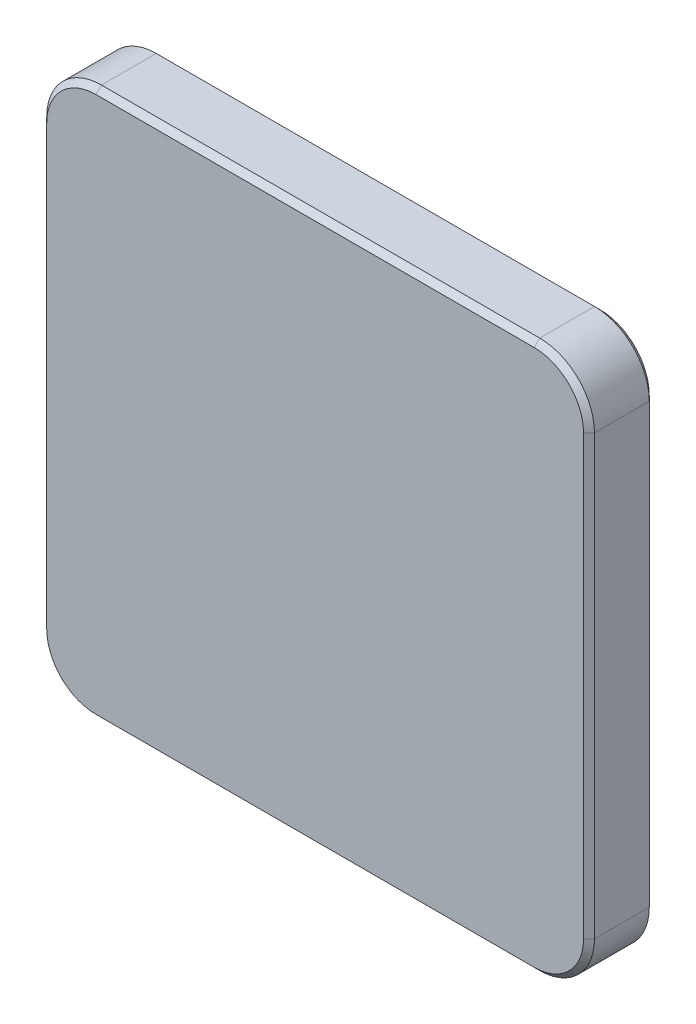
from build123d import *

# Parameters (mm, degrees)
SKETCH1_W           = 100
SKETCH1_H           = 100
BOSS_EXTRUDE1_DEPTH = 12
FILLET1_R           = 10
CHAMFER1_SIZE       = 1
CHAMFER2_SIZE       = 1


with BuildPart() as part:
    # Sketch1 → Boss-Extrude1 (new body)
    with BuildSketch(Plane.XY):
        Rectangle(SKETCH1_W, SKETCH1_H)
    extrude(amount=BOSS_EXTRUDE1_DEPTH)

    # Fillet1
    fillet1_edges = [part.edges().sort_by_distance(p)[0] for p in [
        (50, -50, 6),
        (-50, -50, 6),
        (-50, 50, 6),
        (50, 50, 6),
    ]]
    fillet(fillet1_edges, radius=FILLET1_R)

    # Chamfer1
    chamfer1_edges = [part.edges().sort_by_distance(p)[0] for p in [
        (-50, 0, 0),
        (50, 0, 0),
        (0, -50, 0),
        (0, 50, 0),
        (47.071067812, 47.071067812, 0),
        (47.071067812, -47.071067812, 0),
        (-47.071067812, -47.071067812, 0),
        (-47.071067812, 47.071067812, 0),
    ]]
    chamfer(chamfer1_edges, length=CHAMFER1_SIZE)

    # Chamfer2
    chamfer2_edges = [part.edges().sort_by_distance(p)[0] for p in [
        (-50, 0, 12),
        (0, 50, 12),
        (50, 0, 12),
        (0, -50, 12),
        (47.071067812, 47.071067812, 12),
        (47.071067812, -47.071067812, 12),
        (-47.071067812, -47.071067812, 12),
        (-47.071067812, 47.071067812, 12),
    ]]
    chamfer(chamfer2_edges, length=CHAMFER2_SIZE)


solid = part.part
